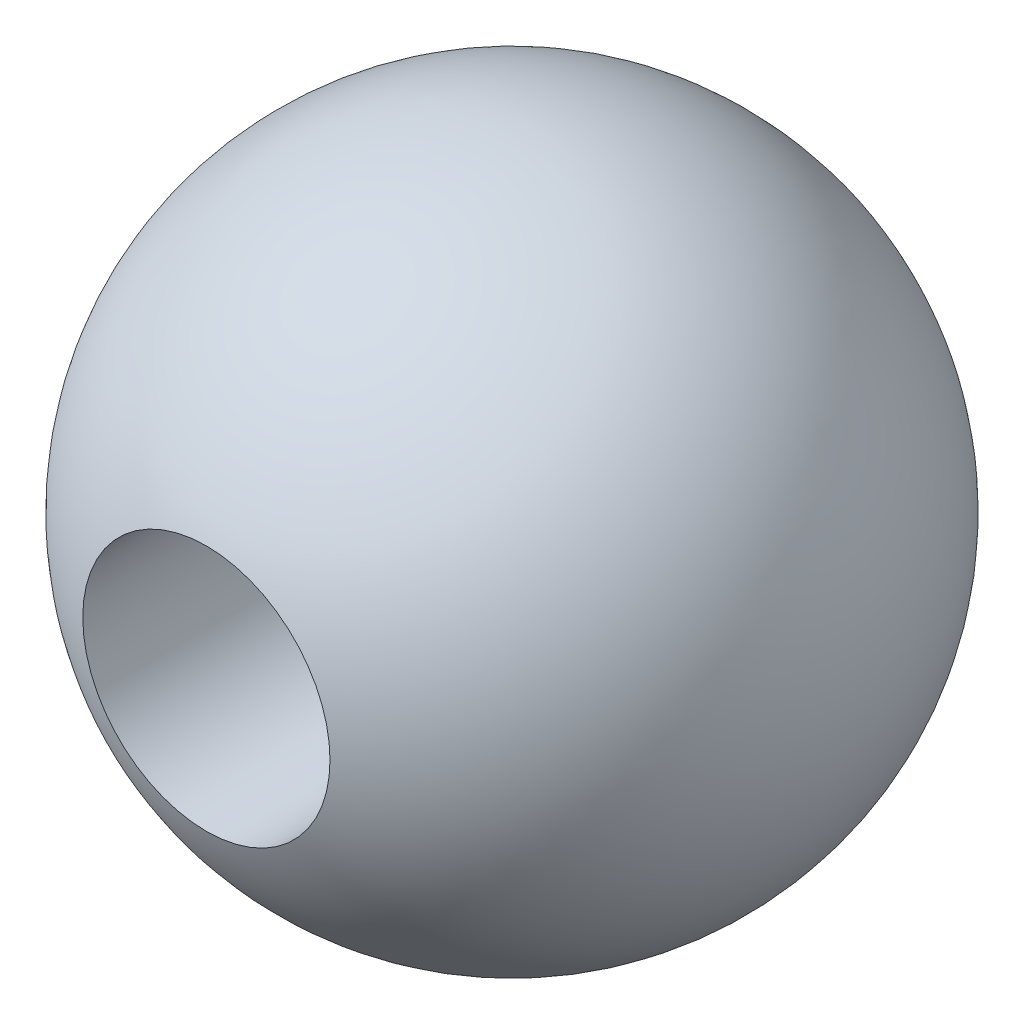
from build123d import *

# Parameters (mm, degrees)
SKETCH2_R          = 0.375
CUT_EXTRUDE1_DEPTH = 0.68


with BuildPart() as part:
    # Sketch1 → Revolve1 (revolve)
    with BuildSketch(Plane.XY):
        with BuildLine():
            Line((0, 1), (0, -1))
            ThreePointArc((0, -1), (-1, 0), (0, 1))
        make_face()
    revolve(axis=Axis((0, 1, 0), (0, -1, 0)))

    # Sketch2 → Cut-Extrude1 (cut)
    with BuildSketch(Plane.XY.offset(1)):
        Circle(SKETCH2_R)
    extrude(amount=-CUT_EXTRUDE1_DEPTH, mode=Mode.SUBTRACT)


solid = part.part
